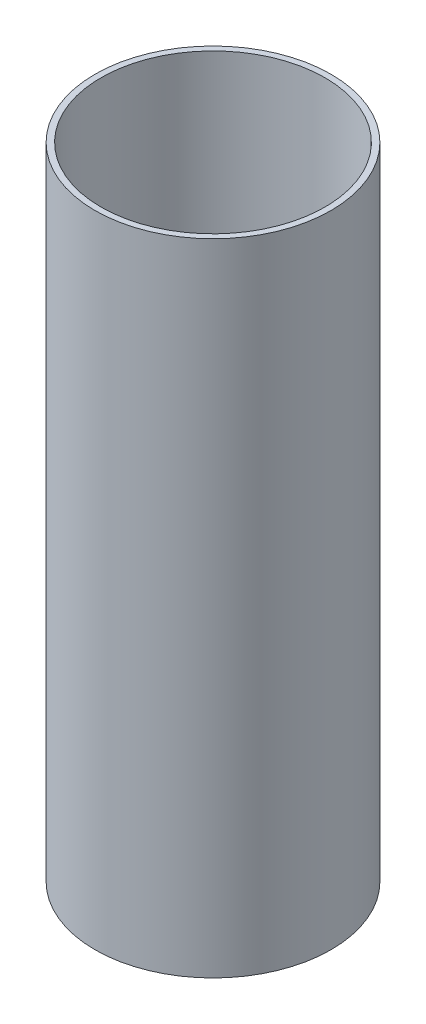
from build123d import *

# Parameters (mm, degrees)
SKETCH1_R           = 93.6625
SKETCH1_R_2         = 88.9
BOSS_EXTRUDE1_DEPTH = 254


with BuildPart() as part:
    # Sketch1 → Boss-Extrude1 (new body, symmetric)
    with BuildSketch(Plane(origin=(0, 0, 0), x_dir=(1, 0, 0), z_dir=(0, 1, 0))):
        Circle(SKETCH1_R)
        Circle(SKETCH1_R_2, mode=Mode.SUBTRACT)
    extrude(amount=BOSS_EXTRUDE1_DEPTH, both=True)


solid = part.part
